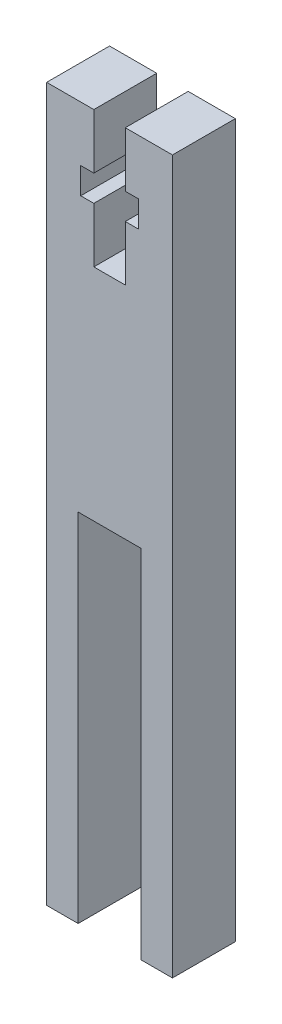
from build123d import *

# Parameters (mm, degrees)
EXTRUDE_1_DEPTH = 6


with BuildPart() as part:
    # Эскиз1 → Бобышка-Вытянуть1 (new body)
    with BuildSketch(Plane.XY):
        Polygon((-1.5, 68), (-1.5, 62.75), (-2.75, 62.75), (-2.75, 60.25), (-1.5, 60.25), (-1.5, 55), (1.5, 55), (1.5, 60.25), (2.75, 60.25), (2.75, 62.75), (1.5, 62.75), (1.5, 68), (6, 68), (6, 0), (3, 0), (3, 34), (-3, 34), (-3, 0), (-6, 0), (-6, 68), align=None)
    extrude(amount=EXTRUDE_1_DEPTH)


solid = part.part
